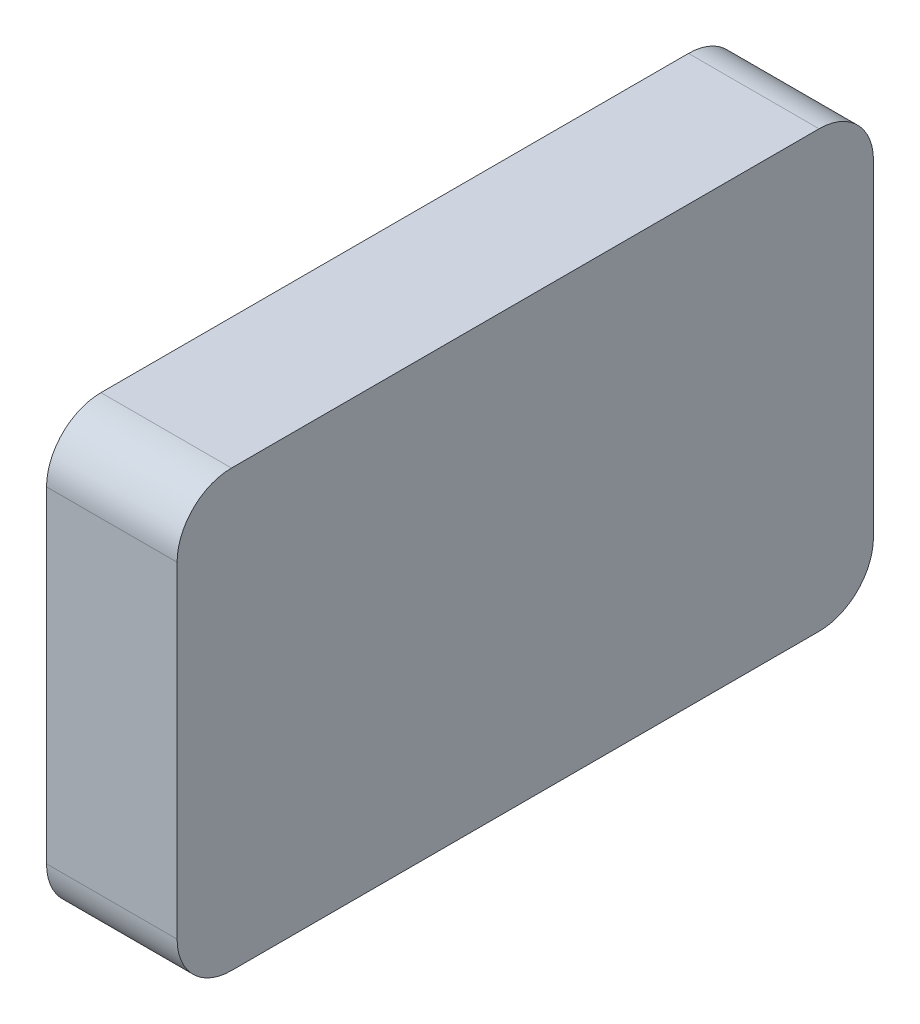
from build123d import *

# Parameters (mm, degrees)
EXTRUDE_1_DEPTH     = 12
SKETCH_2_R          = 8
CUT_EXTRUDE_1_DEPTH = 8
SKETCH_3_R          = 2.5
CUT_EXTRUDE_2_DEPTH = 10


with BuildPart() as part:
    # 草图1 → 凸台-拉伸1 (new body)
    with BuildSketch(Plane(origin=(0, 0, 0), x_dir=(0, 0, -1), z_dir=(1, 0, 0))):
        with BuildLine():
            Line((-27, 20), (27, 20))
            ThreePointArc((27, 20), (30.535533906, 18.535533906), (32, 15))
            Line((32, 15), (32, -15))
            ThreePointArc((32, -15), (30.535533906, -18.535533906), (27, -20))
            Line((27, -20), (-27, -20))
            ThreePointArc((-27, -20), (-30.535533906, -18.535533906), (-32, -15))
            Line((-32, -15), (-32, 15))
            ThreePointArc((-32, 15), (-30.535533906, 18.535533906), (-27, 20))
        make_face()
    extrude(amount=EXTRUDE_1_DEPTH)

    # 草图2 → 切除-拉伸1 (cut)
    with BuildSketch(Plane.ZY):
        Circle(SKETCH_2_R)
    extrude(amount=-CUT_EXTRUDE_1_DEPTH, mode=Mode.SUBTRACT)

    # 草图3 → 切除-拉伸2 (cut)
    with BuildSketch(Plane.XZ.offset(20)):
        with Locations((4, 0)):
            Circle(SKETCH_3_R)
    extrude(amount=-CUT_EXTRUDE_2_DEPTH, mode=Mode.SUBTRACT)


solid = part.part
